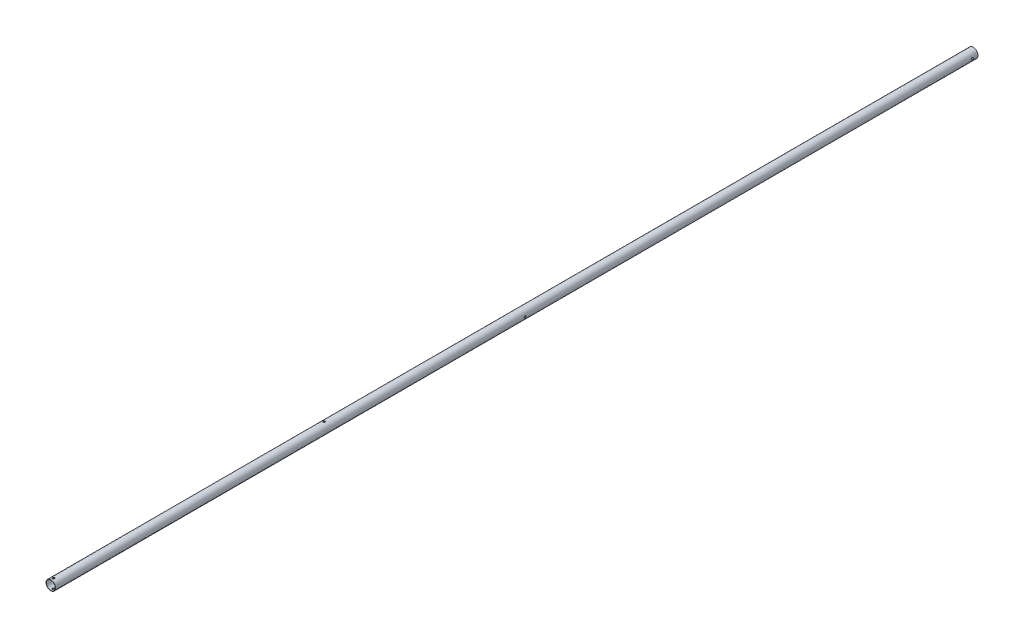
from build123d import *

# Parameters (mm, degrees)
SKETCH1_R               = 12.7
SKETCH1_R_2             = 11.90625
BOSS_EXTRUDE1_DEPTH     = 2443.872227937
SKETCH4_W               = 2.75
SKETCH4_H               = 12.7
SKETCH12_W              = 2.75
SKETCH12_H              = 12.7
SKETCH13_R              = 2.750000003
CUT_EXTRUDE1_DEPTH      = 13.7000001
CUT_EXTRUDE1_DEPTH_BACK = 13.7000001
SKETCH14_R              = 2.5
CUT_EXTRUDE2_DEPTH      = 13.7000001
CUT_EXTRUDE2_DEPTH_BACK = 13.7000001


with BuildPart() as part:
    # Sketch1 → Boss-Extrude1 (new body)
    with BuildSketch(Plane.XY):
        Circle(SKETCH1_R)
        Circle(SKETCH1_R_2, mode=Mode.SUBTRACT)
    extrude(amount=BOSS_EXTRUDE1_DEPTH)

    # Sketch4 → M5 Clearance Hole1 (revolve, cut)
    with BuildSketch(Plane(origin=(0, 0, 2436.622227937), x_dir=(0, 0, -1), z_dir=(1, 0, 0))):
        with Locations((1.375, 6.35)):
            Rectangle(SKETCH4_W, SKETCH4_H)
    m5_clearance_hole1 = revolve(axis=Axis((0, -6.35, 2436.622227937), (0, 1, 0)), mode=Mode.SUBTRACT)

    # Mirror1: M5 Clearance Hole1 across plane
    add(m5_clearance_hole1.mirror(Plane.ZX), mode=Mode.SUBTRACT)

    # Sketch12 → M5 Clearance Hole3 (revolve, cut)
    with BuildSketch(Plane(origin=(0, 0, 15), x_dir=(0, 0, 1), z_dir=(0, 1, 0))):
        with Locations((1.375, 6.35)):
            Rectangle(SKETCH12_W, SKETCH12_H)
    m5_clearance_hole3 = revolve(axis=Axis((-6.35, 0, 15), (1, 0, 0)), mode=Mode.SUBTRACT)

    # Mirror3: M5 Clearance Hole3 across plane
    add(m5_clearance_hole3.mirror(Plane(origin=(0, 0, 0), x_dir=(0, 0, 1), z_dir=(1, 0, 0))), mode=Mode.SUBTRACT)

    # Sketch13 → Cut-Extrude1 (cut, two sides)
    with BuildSketch(Plane(origin=(0, 0, 0), x_dir=(1, 0, 0), z_dir=(0, 1, 0))) as cut_extrude1_sk:
        with Locations((-0.739798723, -1718.754532743)):
            Circle(SKETCH13_R)
    extrude(amount=CUT_EXTRUDE1_DEPTH, mode=Mode.SUBTRACT)
    extrude(cut_extrude1_sk.sketch, amount=-CUT_EXTRUDE1_DEPTH_BACK, mode=Mode.SUBTRACT)

    # Sketch14 → Cut-Extrude2 (cut, two sides)
    with BuildSketch(Plane(origin=(0, 0, 0), x_dir=(0, 0, -1), z_dir=(1, 0, 0))) as cut_extrude2_sk:
        with Locations((-1200, 0)):
            Circle(SKETCH14_R)
    extrude(amount=CUT_EXTRUDE2_DEPTH, mode=Mode.SUBTRACT)
    extrude(cut_extrude2_sk.sketch, amount=-CUT_EXTRUDE2_DEPTH_BACK, mode=Mode.SUBTRACT)


solid = part.part
